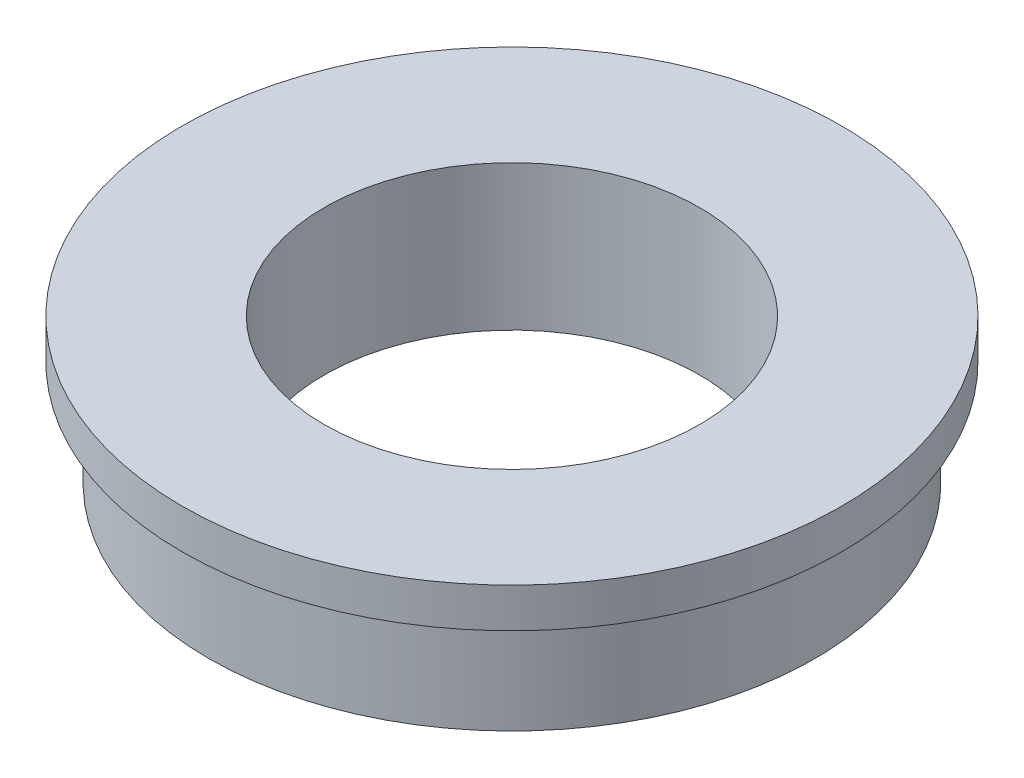
from build123d import *


with BuildPart() as part:
    # Esquisse1 → Révolution1 (revolve)
    with BuildSketch(Plane.XY, mode=Mode.PRIVATE) as r_volution1_sk:
        Polygon((-14.25, -8), (-14.25, 3), (-25, 3), (-25, 0), (-23, 0), (-23, -8), align=None)
    revolve(r_volution1_sk.sketch.rotate(Axis((0, 27.606261023, 0), (0, -1, 0)), 270), axis=Axis((0, 27.606261023, 0), (0, -1, 0)))  # turned: the seam where the file's is


solid = part.part
